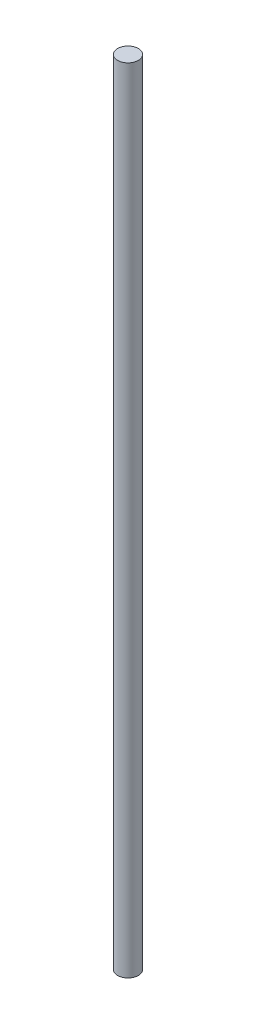
from build123d import *

# Parameters (mm, degrees)
SKETCH1_R           = 0.3
BOSS_EXTRUDE1_DEPTH = 23


with BuildPart() as part:
    # Sketch1 → Boss-Extrude1 (new body)
    with BuildSketch(Plane(origin=(0, 0, 0), x_dir=(1, 0, 0), z_dir=(0, 1, 0))):
        Circle(SKETCH1_R)
    extrude(amount=BOSS_EXTRUDE1_DEPTH)


solid = part.part
